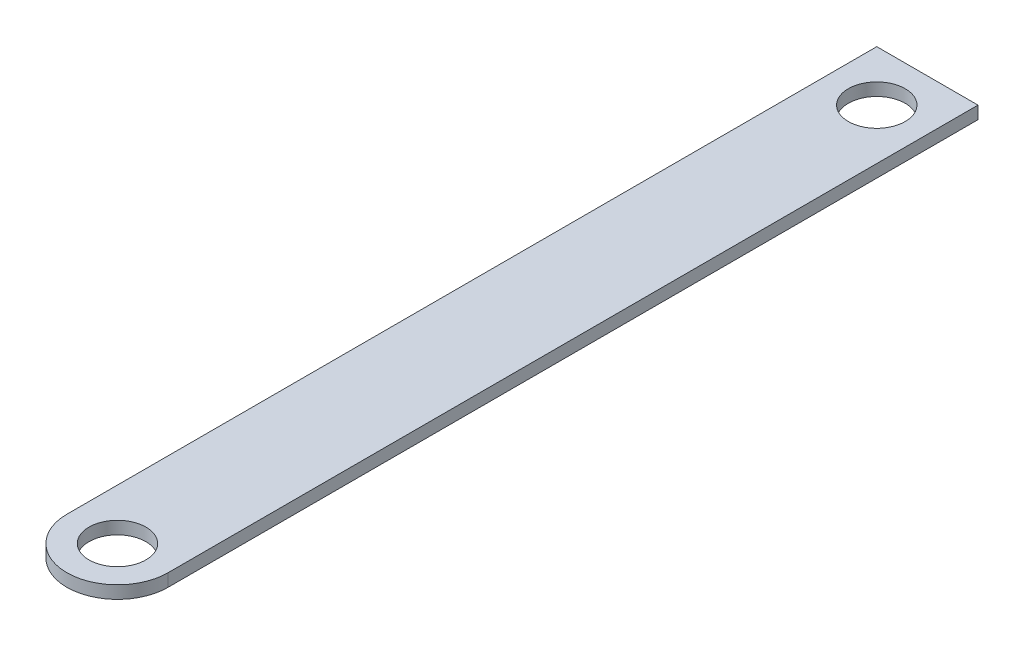
from build123d import *

# Parameters (mm, degrees)
SKETCH1_R           = 14.2748
BOSS_EXTRUDE1_DEPTH = 6.35


with BuildPart() as part:
    # Sketch1 → Boss-Extrude1 (new body)
    with BuildSketch(Plane(origin=(0, 0, 0), x_dir=(1, 0, 0), z_dir=(0, 1, 0))):
        with BuildLine():
            Line((0, 0), (0, 406.4))
            Line((0, 406.4), (50.8, 406.4))
            Line((50.8, 406.4), (50.8, 0))
            ThreePointArc((50.8, 0), (43.360512242, -17.960512242), (25.4, -25.4))
            ThreePointArc((25.4, -25.4), (7.439487758, -17.960512242), (0, 0))
        make_face()
        with Locations((25.4, 0)):
            Circle(SKETCH1_R, mode=Mode.SUBTRACT)
        with Locations((25.4, 381)):
            Circle(SKETCH1_R, mode=Mode.SUBTRACT)
    extrude(amount=BOSS_EXTRUDE1_DEPTH)


solid = part.part
